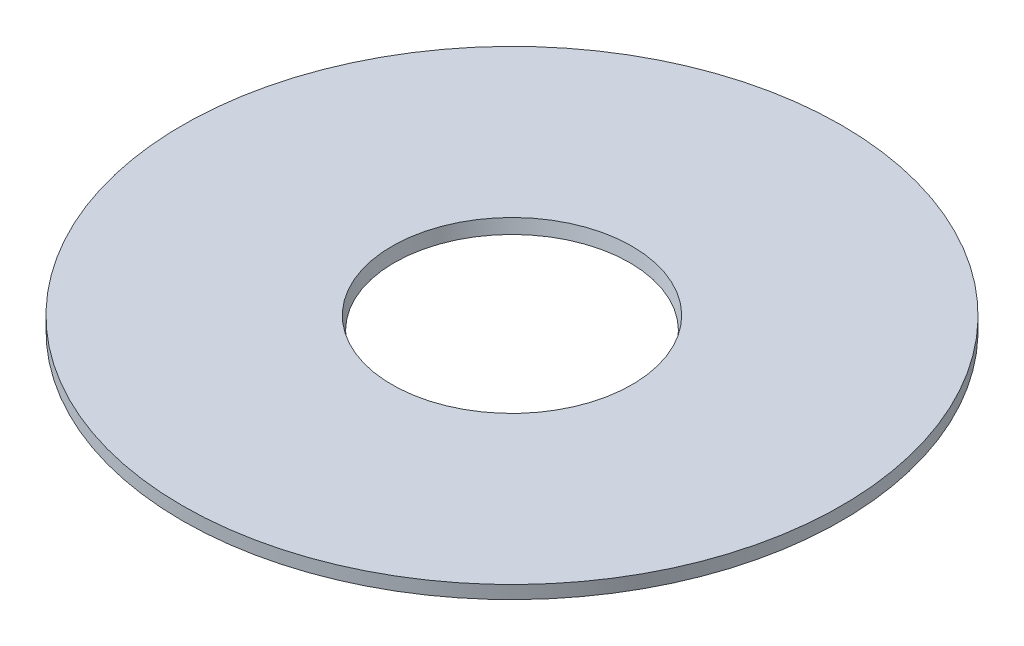
from build123d import *


with BuildPart() as part:
    # Sketch1 → Revolve1 (revolve)
    with BuildSketch(Plane.XY):
        Polygon((45.881634904, -5), (126, -5), (126, 0), (45.881634904, 0), (45, -5), align=None)
    revolve(axis=Axis((0, 0, 0), (0, 1, 0)))


solid = part.part
